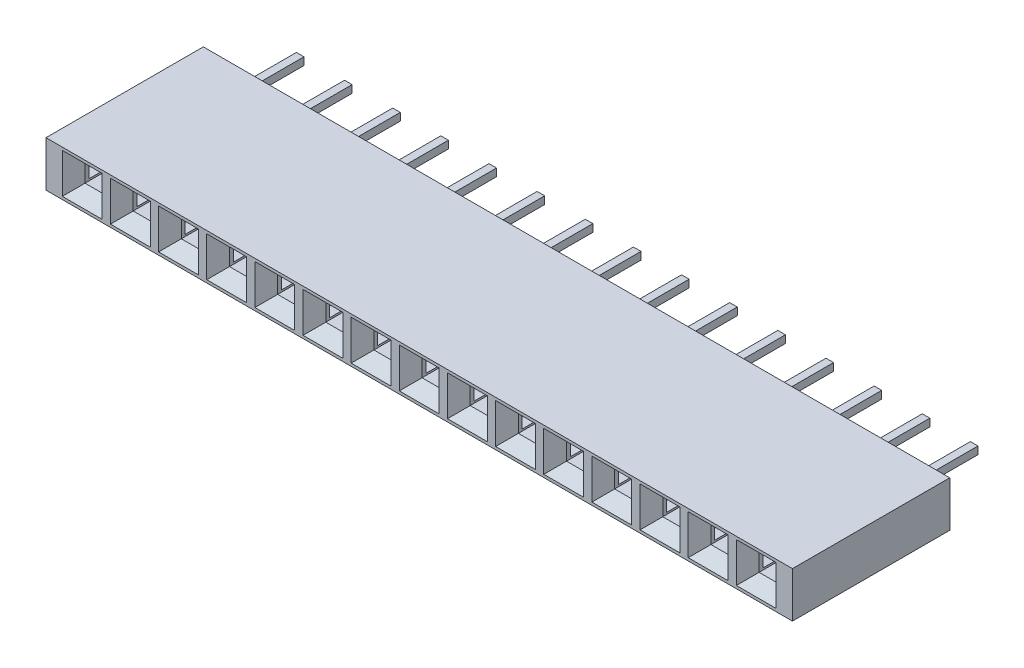
from build123d import *

# Parameters (mm, degrees)
SKETCH_246_W              = 2.54
SKETCH_246_H              = 2.4
EXTRUDE_723_DEPTH         = 6.7
EXTRUDE_723_DEPTH_BACK    = 0.4
SKETCH_777_W              = 2.54
SKETCH_777_H              = 0.75
EXTRUDE_1156_DEPTH        = 0.4
SKETCH_1210_W             = 2.54
SKETCH_1210_H             = 2.4
SKETCH_1210_W_2           = 0.9
SKETCH_1210_H_2           = 0.9
EXTRUDE_1495_DEPTH        = 0.8
CHAMFER_1556_SIZE         = 0.6
PATTERN_LINEAR_1682_COUNT = 15
PATTERN_LINEAR_1682_PITCH = 2.54
EXTRUDE_1_DEPTH           = 0.64
EXTRUDE_START             = -38.74
EXTRUDE_2_DEPTH           = 0.64
SKETCH1_W                 = 0.4
SKETCH1_H                 = 0.4
BOSS_EXTRUDE1_DEPTH       = 3.2
BOSS_EXTRUDE1_2_DEPTH     = 3.2
BOSS_EXTRUDE1_3_DEPTH     = 3.2
BOSS_EXTRUDE1_4_DEPTH     = 3.2
BOSS_EXTRUDE1_5_DEPTH     = 3.2
BOSS_EXTRUDE1_6_DEPTH     = 3.2
BOSS_EXTRUDE1_7_DEPTH     = 3.2
BOSS_EXTRUDE1_8_DEPTH     = 3.2
BOSS_EXTRUDE1_9_DEPTH     = 3.2
BOSS_EXTRUDE1_10_DEPTH    = 3.2
BOSS_EXTRUDE1_11_DEPTH    = 3.2
BOSS_EXTRUDE1_12_DEPTH    = 3.2
BOSS_EXTRUDE1_13_DEPTH    = 3.2
BOSS_EXTRUDE1_14_DEPTH    = 3.2
BOSS_EXTRUDE1_15_DEPTH    = 3.2
SKETCH2_W                 = 39.38
SKETCH2_H                 = 0.9
BOSS_EXTRUDE2_DEPTH       = 0.4


with BuildPart() as part:
    # Sketch 246 → Extrude 723 (new body, two sides)
    with BuildSketch(Plane.XY) as extrude_723_sk:
        Rectangle(SKETCH_246_W, SKETCH_246_H)
        Polygon((-1, 0.35), (-0.45, 0.35), (-0.45, 0.45), (0.45, 0.45), (0.45, 0.35), (1, 0.35), (1, -0.35), (0.45, -0.35), (0.45, -0.45), (-0.45, -0.45), (-0.45, -0.35), (-1, -0.35), align=None, mode=Mode.SUBTRACT)
    extrude(amount=EXTRUDE_723_DEPTH)
    extrude(extrude_723_sk.sketch, amount=-EXTRUDE_723_DEPTH_BACK)

    # Sketch 777 → Extrude 1156 (add)
    with BuildSketch(Plane(origin=(0, 0, -0.4), x_dir=(-1, 0, 0), z_dir=(0, 0, -1))):
        with Locations((0, -0.825)):
            Rectangle(SKETCH_777_W, SKETCH_777_H)
        with Locations((0, 0.825)):
            Rectangle(SKETCH_777_W, SKETCH_777_H)
    extrude(amount=EXTRUDE_1156_DEPTH)

    # Sketch 1210 → Extrude 1495 (add)
    with BuildSketch(Plane.XY.offset(6.7)):
        Rectangle(SKETCH_1210_W, SKETCH_1210_H)
        Rectangle(SKETCH_1210_W_2, SKETCH_1210_H_2, mode=Mode.SUBTRACT)
    extrude(amount=EXTRUDE_1495_DEPTH)

    # Chamfer 1556
    chamfer_1556_edges = [part.edges().sort_by_distance(p)[0] for p in [
        (0.45, 0, 7.5),
        (0, 0.45, 7.5),
        (-0.45, 0, 7.5),
        (0, -0.45, 7.5),
    ]]
    chamfer(chamfer_1556_edges, length=CHAMFER_1556_SIZE)


with BuildPart() as pattern_linear_1682_1:
    # Pattern Linear 1682: pattern copy
    add(part.part.moved(Location(Vector(-1, 0, 0) * (1 * PATTERN_LINEAR_1682_PITCH))))


with BuildPart() as pattern_linear_1682_2:
    # Pattern Linear 1682: pattern copy
    add(part.part.moved(Location(Vector(-1, 0, 0) * (2 * PATTERN_LINEAR_1682_PITCH))))


with BuildPart() as pattern_linear_1682_3:
    # Pattern Linear 1682: pattern copy
    add(part.part.moved(Location(Vector(-1, 0, 0) * (3 * PATTERN_LINEAR_1682_PITCH))))


with BuildPart() as pattern_linear_1682_4:
    # Pattern Linear 1682: pattern copy
    add(part.part.moved(Location(Vector(-1, 0, 0) * (4 * PATTERN_LINEAR_1682_PITCH))))


with BuildPart() as pattern_linear_1682_5:
    # Pattern Linear 1682: pattern copy
    add(part.part.moved(Location(Vector(-1, 0, 0) * (5 * PATTERN_LINEAR_1682_PITCH))))


with BuildPart() as pattern_linear_1682_6:
    # Pattern Linear 1682: pattern copy
    add(part.part.moved(Location(Vector(-1, 0, 0) * (6 * PATTERN_LINEAR_1682_PITCH))))


with BuildPart() as pattern_linear_1682_7:
    # Pattern Linear 1682: pattern copy
    add(part.part.moved(Location(Vector(-1, 0, 0) * (7 * PATTERN_LINEAR_1682_PITCH))))


with BuildPart() as pattern_linear_1682_8:
    # Pattern Linear 1682: pattern copy
    add(part.part.moved(Location(Vector(-1, 0, 0) * (8 * PATTERN_LINEAR_1682_PITCH))))


with BuildPart() as pattern_linear_1682_9:
    # Pattern Linear 1682: pattern copy
    add(part.part.moved(Location(Vector(-1, 0, 0) * (9 * PATTERN_LINEAR_1682_PITCH))))


with BuildPart() as pattern_linear_1682_10:
    # Pattern Linear 1682: pattern copy
    add(part.part.moved(Location(Vector(-1, 0, 0) * (10 * PATTERN_LINEAR_1682_PITCH))))


with BuildPart() as pattern_linear_1682_11:
    # Pattern Linear 1682: pattern copy
    add(part.part.moved(Location(Vector(-1, 0, 0) * (11 * PATTERN_LINEAR_1682_PITCH))))


with BuildPart() as pattern_linear_1682_12:
    # Pattern Linear 1682: pattern copy
    add(part.part.moved(Location(Vector(-1, 0, 0) * (12 * PATTERN_LINEAR_1682_PITCH))))


with BuildPart() as pattern_linear_1682_13:
    # Pattern Linear 1682: pattern copy
    add(part.part.moved(Location(Vector(-1, 0, 0) * (13 * PATTERN_LINEAR_1682_PITCH))))


with BuildPart() as pattern_linear_1682_14:
    # Pattern Linear 1682: pattern copy
    add(part.part.moved(Location(Vector(-1, 0, 0) * (14 * PATTERN_LINEAR_1682_PITCH))))


with BuildPart() as part_1:
    add(part.part)

    # Combine 1798: union Pattern Linear 1682_14, Pattern Linear 1682_13, Pattern Linear 1682_12, Pattern Linear 1682_11, Pattern Linear 1682_10, Pattern Linear 1682_9, Pattern Linear 1682_8, Pattern Linear 1682_7, Pattern Linear 1682_6, Pattern Linear 1682_5, Pattern Linear 1682_4, Pattern Linear 1682_3, Pattern Linear 1682_2, Pattern Linear 1682_1
    add(pattern_linear_1682_14.part)
    add(pattern_linear_1682_13.part)
    add(pattern_linear_1682_12.part)
    add(pattern_linear_1682_11.part)
    add(pattern_linear_1682_10.part)
    add(pattern_linear_1682_9.part)
    add(pattern_linear_1682_8.part)
    add(pattern_linear_1682_7.part)
    add(pattern_linear_1682_6.part)
    add(pattern_linear_1682_5.part)
    add(pattern_linear_1682_4.part)
    add(pattern_linear_1682_3.part)
    add(pattern_linear_1682_2.part)
    add(pattern_linear_1682_1.part)

    # Sketch 2606 → Бобышка-БоковаяНакладка1 (add)
    with BuildSketch(Plane(origin=(1.27, 0, 0), x_dir=(0, 0, -1), z_dir=(1, 0, 0))):
        Polygon((0.8, 1.2), (0.8, 0.45), (0.4, 0.45), (0.4, -0.45), (0.8, -0.45), (0.8, -1.2), (-7.5, -1.2), (-7.5, 1.2), align=None)
    extrude(amount=EXTRUDE_1_DEPTH)

    # Эскиз-БоковаяНакладка<2> → Бобышка-БоковаяНакладка2 (add)
    with BuildSketch(Plane(origin=(1.27, 0, 0), x_dir=(0, 0, -1), z_dir=(1, 0, 0)).offset(EXTRUDE_START)):
        Polygon((0.8, 1.2), (0.8, 0.45), (0.4, 0.45), (0.4, -0.45), (0.8, -0.45), (0.8, -1.2), (-7.5, -1.2), (-7.5, 1.2), align=None)
    extrude(amount=EXTRUDE_2_DEPTH)



with BuildPart() as body_2:
    # Sketch1 → Boss-Extrude1 (new body)
    with BuildSketch(Plane(origin=(0, 0, -0.8), x_dir=(-1, 0, 0), z_dir=(0, 0, -1))):
        with Locations((2.54, 0)):
            Rectangle(SKETCH1_W, SKETCH1_H)
    extrude(amount=BOSS_EXTRUDE1_DEPTH)


with BuildPart() as body_3:
    # Sketch1 → Boss-Extrude1 2 (new body)
    with BuildSketch(Plane(origin=(0, 0, -0.8), x_dir=(-1, 0, 0), z_dir=(0, 0, -1))):
        Rectangle(SKETCH1_W, SKETCH1_H)
    extrude(amount=BOSS_EXTRUDE1_2_DEPTH)


with BuildPart() as body_4:
    # Sketch1 → Boss-Extrude1 3 (new body)
    with BuildSketch(Plane(origin=(0, 0, -0.8), x_dir=(-1, 0, 0), z_dir=(0, 0, -1))):
        with Locations((5.08, 0)):
            Rectangle(SKETCH1_W, SKETCH1_H)
    extrude(amount=BOSS_EXTRUDE1_3_DEPTH)


with BuildPart() as body_5:
    # Sketch1 → Boss-Extrude1 4 (new body)
    with BuildSketch(Plane(origin=(0, 0, -0.8), x_dir=(-1, 0, 0), z_dir=(0, 0, -1))):
        with Locations((7.62, 0)):
            Rectangle(SKETCH1_W, SKETCH1_H)
    extrude(amount=BOSS_EXTRUDE1_4_DEPTH)


with BuildPart() as body_6:
    # Sketch1 → Boss-Extrude1 5 (new body)
    with BuildSketch(Plane(origin=(0, 0, -0.8), x_dir=(-1, 0, 0), z_dir=(0, 0, -1))):
        with Locations((10.16, 0)):
            Rectangle(SKETCH1_W, SKETCH1_H)
    extrude(amount=BOSS_EXTRUDE1_5_DEPTH)


with BuildPart() as body_7:
    # Sketch1 → Boss-Extrude1 6 (new body)
    with BuildSketch(Plane(origin=(0, 0, -0.8), x_dir=(-1, 0, 0), z_dir=(0, 0, -1))):
        with Locations((12.7, 0)):
            Rectangle(SKETCH1_W, SKETCH1_H)
    extrude(amount=BOSS_EXTRUDE1_6_DEPTH)


with BuildPart() as body_8:
    # Sketch1 → Boss-Extrude1 7 (new body)
    with BuildSketch(Plane(origin=(0, 0, -0.8), x_dir=(-1, 0, 0), z_dir=(0, 0, -1))):
        with Locations((15.24, 0)):
            Rectangle(SKETCH1_W, SKETCH1_H)
    extrude(amount=BOSS_EXTRUDE1_7_DEPTH)


with BuildPart() as body_9:
    # Sketch1 → Boss-Extrude1 8 (new body)
    with BuildSketch(Plane(origin=(0, 0, -0.8), x_dir=(-1, 0, 0), z_dir=(0, 0, -1))):
        with Locations((17.78, 0)):
            Rectangle(SKETCH1_W, SKETCH1_H)
    extrude(amount=BOSS_EXTRUDE1_8_DEPTH)


with BuildPart() as body_10:
    # Sketch1 → Boss-Extrude1 9 (new body)
    with BuildSketch(Plane(origin=(0, 0, -0.8), x_dir=(-1, 0, 0), z_dir=(0, 0, -1))):
        with Locations((20.32, 0)):
            Rectangle(SKETCH1_W, SKETCH1_H)
    extrude(amount=BOSS_EXTRUDE1_9_DEPTH)


with BuildPart() as body_11:
    # Sketch1 → Boss-Extrude1 10 (new body)
    with BuildSketch(Plane(origin=(0, 0, -0.8), x_dir=(-1, 0, 0), z_dir=(0, 0, -1))):
        with Locations((22.86, 0)):
            Rectangle(SKETCH1_W, SKETCH1_H)
    extrude(amount=BOSS_EXTRUDE1_10_DEPTH)


with BuildPart() as body_12:
    # Sketch1 → Boss-Extrude1 11 (new body)
    with BuildSketch(Plane(origin=(0, 0, -0.8), x_dir=(-1, 0, 0), z_dir=(0, 0, -1))):
        with Locations((25.4, 0)):
            Rectangle(SKETCH1_W, SKETCH1_H)
    extrude(amount=BOSS_EXTRUDE1_11_DEPTH)


with BuildPart() as body_13:
    # Sketch1 → Boss-Extrude1 12 (new body)
    with BuildSketch(Plane(origin=(0, 0, -0.8), x_dir=(-1, 0, 0), z_dir=(0, 0, -1))):
        with Locations((27.94, 0)):
            Rectangle(SKETCH1_W, SKETCH1_H)
    extrude(amount=BOSS_EXTRUDE1_12_DEPTH)


with BuildPart() as body_14:
    # Sketch1 → Boss-Extrude1 13 (new body)
    with BuildSketch(Plane(origin=(0, 0, -0.8), x_dir=(-1, 0, 0), z_dir=(0, 0, -1))):
        with Locations((30.48, 0)):
            Rectangle(SKETCH1_W, SKETCH1_H)
    extrude(amount=BOSS_EXTRUDE1_13_DEPTH)


with BuildPart() as body_15:
    # Sketch1 → Boss-Extrude1 14 (new body)
    with BuildSketch(Plane(origin=(0, 0, -0.8), x_dir=(-1, 0, 0), z_dir=(0, 0, -1))):
        with Locations((33.02, 0)):
            Rectangle(SKETCH1_W, SKETCH1_H)
    extrude(amount=BOSS_EXTRUDE1_14_DEPTH)


with BuildPart() as body_16:
    # Sketch1 → Boss-Extrude1 15 (new body)
    with BuildSketch(Plane(origin=(0, 0, -0.8), x_dir=(-1, 0, 0), z_dir=(0, 0, -1))):
        with Locations((35.56, 0)):
            Rectangle(SKETCH1_W, SKETCH1_H)
    extrude(amount=BOSS_EXTRUDE1_15_DEPTH)


with BuildPart() as part_2:
    add(part_1.part)

    add(body_2.part)  # Boss-Extrude2 merges body 2

    add(body_3.part)  # Boss-Extrude2 merges body 3

    add(body_4.part)  # Boss-Extrude2 merges body 4

    add(body_5.part)  # Boss-Extrude2 merges body 5

    add(body_6.part)  # Boss-Extrude2 merges body 6

    add(body_7.part)  # Boss-Extrude2 merges body 7

    add(body_8.part)  # Boss-Extrude2 merges body 8

    add(body_9.part)  # Boss-Extrude2 merges body 9

    add(body_10.part)  # Boss-Extrude2 merges body 10

    add(body_11.part)  # Boss-Extrude2 merges body 11

    add(body_12.part)  # Boss-Extrude2 merges body 12

    add(body_13.part)  # Boss-Extrude2 merges body 13

    add(body_14.part)  # Boss-Extrude2 merges body 14

    add(body_15.part)  # Boss-Extrude2 merges body 15

    add(body_16.part)  # Boss-Extrude2 merges body 16
    # Sketch2 → Boss-Extrude2 (add)
    with BuildSketch(Plane(origin=(0, 0, -0.4), x_dir=(-1, 0, 0), z_dir=(0, 0, -1))):
        with Locations((17.78, 0)):
            Rectangle(SKETCH2_W, SKETCH2_H)
    extrude(amount=BOSS_EXTRUDE2_DEPTH)


solid = part_2.part
